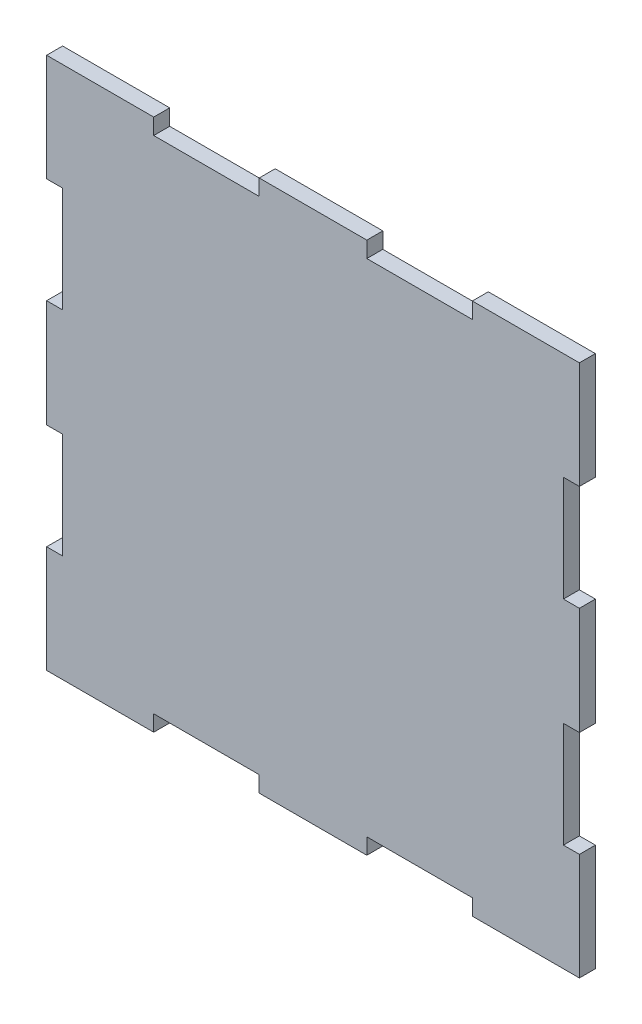
from build123d import *

# Parameters (mm, degrees)
BOSS_EXTRUDE1_DEPTH = 3


with BuildPart() as part:
    # Sketch1 → Boss-Extrude1 (new body)
    with BuildSketch(Plane.XY):
        Polygon((60.1, 97), (60.1, 100), (39.9, 100), (39.9, 97), (20.1, 97), (20.1, 100), (0, 100), (0, 79.9), (3, 79.9), (3, 60.1), (0, 60.1), (0, 39.9), (3, 39.9), (3, 20.1), (0, 20.1), (0, 0), (20.1, 0), (20.1, 3), (39.9, 3), (39.9, 0), (60.1, 0), (60.1, 3), (79.9, 3), (79.9, 0), (100, 0), (100, 20.1), (97, 20.1), (97, 39.9), (100, 39.9), (100, 60.1), (97, 60.1), (97, 79.9), (100, 79.9), (100, 100), (79.9, 100), (79.9, 97), align=None)
    extrude(amount=BOSS_EXTRUDE1_DEPTH)


solid = part.part
